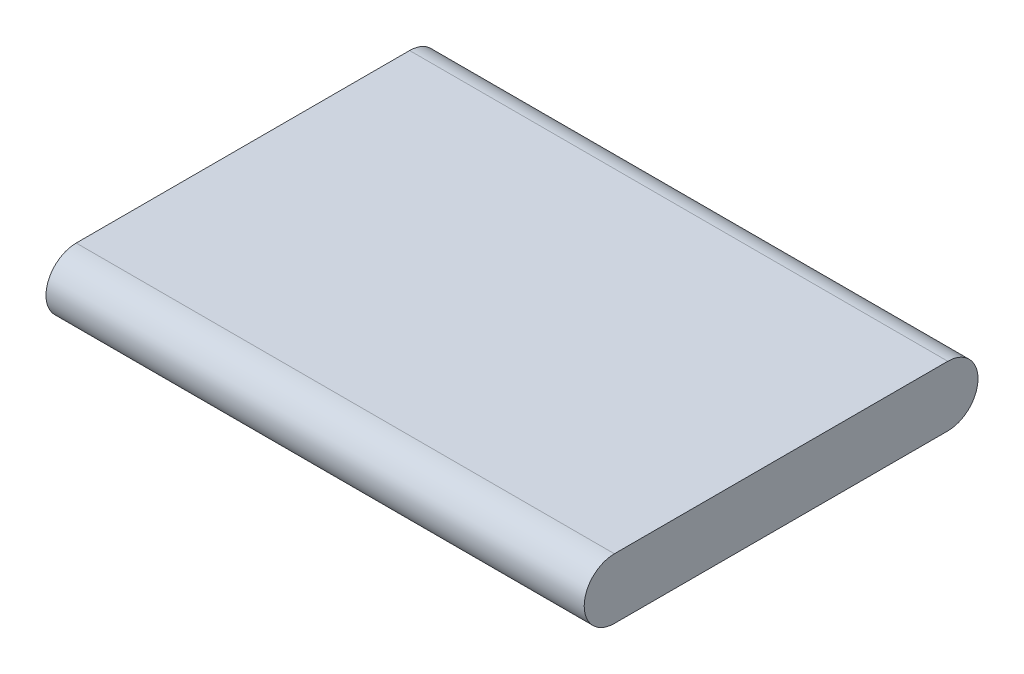
from build123d import *

# Parameters (mm, degrees)
BOSS_EXTRUDE1_DEPTH = 41


with BuildPart() as part:
    # Sketch1 → Boss-Extrude1 (new body)
    with BuildSketch(Plane(origin=(0, 0, 0), x_dir=(0, 0, -1), z_dir=(1, 0, 0))):
        with BuildLine():
            Line((-10.813544484, 2.3), (14.586455516, 2.3))
            ThreePointArc((14.586455516, 2.3), (16.886455516, 0), (14.586455516, -2.3))
            Line((14.586455516, -2.3), (-10.813544484, -2.3))
            ThreePointArc((-10.813544484, -2.3), (-13.113544484, 0), (-10.813544484, 2.3))
        make_face()
    extrude(amount=BOSS_EXTRUDE1_DEPTH)


solid = part.part
